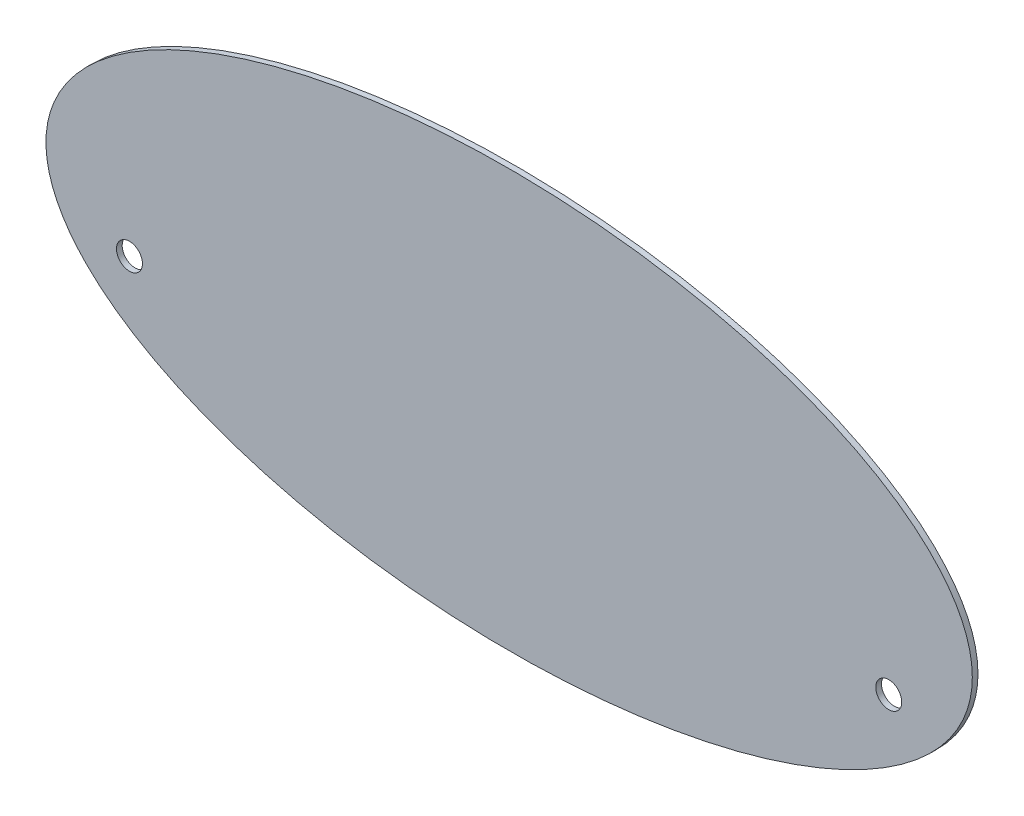
from build123d import *

# Parameters (mm, degrees)
SKETCH1_RX              = 244
SKETCH1_RY              = 110
BOSS_EXTRUDE1_DEPTH     = 3
SKETCH2_R               = 6.83635542
CUT_EXTRUDE1_DEPTH      = 4
CUT_EXTRUDE1_DEPTH_BACK = 1


with BuildPart() as part:
    # Sketch1 → Boss-Extrude1 (new body)
    with BuildSketch(Plane.XY):
        with Locations((0, 0)):
            Ellipse(SKETCH1_RX, SKETCH1_RY)
    extrude(amount=BOSS_EXTRUDE1_DEPTH)

    # Sketch2 → Cut-Extrude1 (cut, two sides)
    with BuildSketch(Plane.XY) as cut_extrude1_sk:
        with Locations((-200, -30)):
            Circle(SKETCH2_R)
        with Locations((200, -30)):
            Circle(SKETCH2_R)
    extrude(amount=CUT_EXTRUDE1_DEPTH, mode=Mode.SUBTRACT)
    extrude(cut_extrude1_sk.sketch, amount=-CUT_EXTRUDE1_DEPTH_BACK, mode=Mode.SUBTRACT)


solid = part.part
